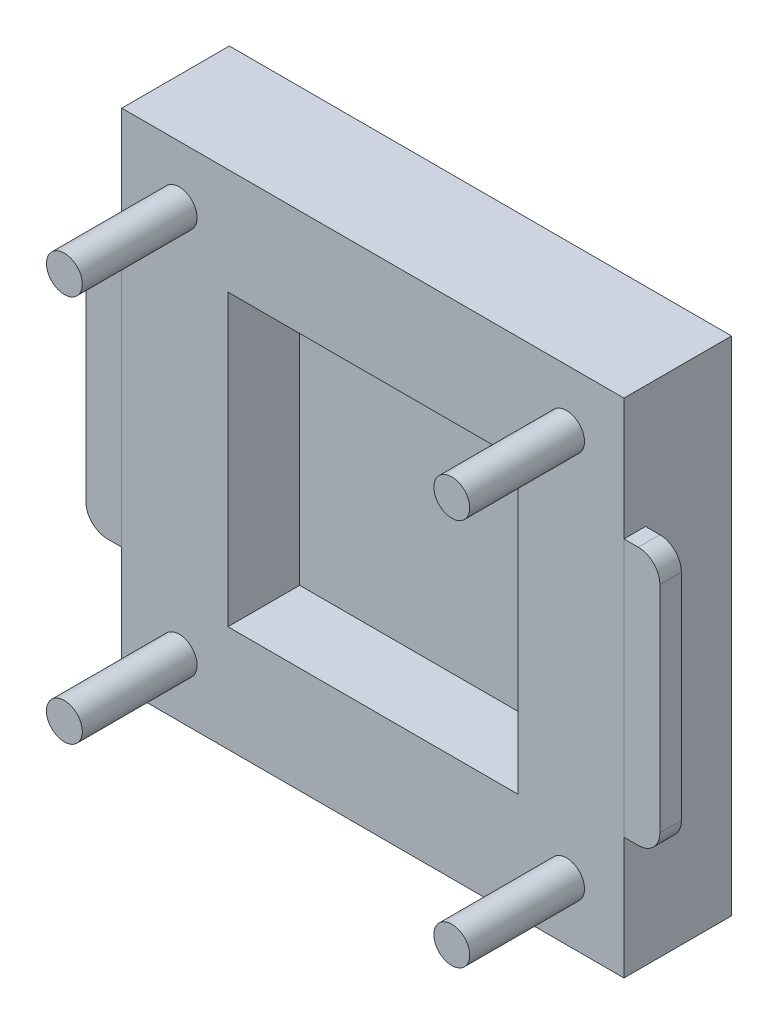
from build123d import *

# Parameters (mm, degrees)
SKETCH_1_W          = 70
SKETCH_1_H          = 70
EXTRUDE_1_DEPTH     = 15
SKETCH_2_W          = 40.4
SKETCH_2_H          = 40.4
CUT_EXTRUDE_1_DEPTH = 10
SKETCH_3_R          = 2.5
EXTRUDE_2_DEPTH     = 16
EXTRUDE_3_DEPTH     = 3
EXTRUDE_3_2_DEPTH   = 3


with BuildPart() as part:
    # 草图1 → 凸台-拉伸1 (new body)
    with BuildSketch(Plane.XY):
        with Locations((35, 35)):
            Rectangle(SKETCH_1_W, SKETCH_1_H)
    extrude(amount=EXTRUDE_1_DEPTH)

    # 草图2 → 切除-拉伸1 (cut)
    with BuildSketch(Plane.XY.offset(15)):
        with Locations((35, 35)):
            Rectangle(SKETCH_2_W, SKETCH_2_H)
    extrude(amount=-CUT_EXTRUDE_1_DEPTH, mode=Mode.SUBTRACT)

    # 草图3 → 凸台-拉伸2 (add)
    with BuildSketch(Plane.XY.offset(15)):
        with Locations((8, 62)):
            Circle(SKETCH_3_R)
        with Locations((62, 62)):
            Circle(SKETCH_3_R)
        with Locations((62, 8)):
            Circle(SKETCH_3_R)
        with Locations((8, 8)):
            Circle(SKETCH_3_R)
    extrude(amount=EXTRUDE_2_DEPTH)


with BuildPart() as body_2:
    # 草图5 → 凸台-拉伸3 (new body)
    with BuildSketch(Plane.XY.offset(15)):
        with BuildLine():
            Line((-2, 53), (0, 53))
            Line((0, 53), (0, 17))
            Line((0, 17), (-2, 17))
            ThreePointArc((-2, 17), (-4.121320344, 17.878679656), (-5, 20))
            Line((-5, 20), (-5, 50))
            ThreePointArc((-5, 50), (-4.121320344, 52.121320344), (-2, 53))
        make_face()
    extrude(amount=-EXTRUDE_3_DEPTH)


with BuildPart() as body_3:
    # 草图5 → Extrude 3 2 (new body)
    with BuildSketch(Plane.XY.offset(15)):
        with BuildLine():
            Line((72, 17), (70, 17))
            Line((70, 17), (70, 53))
            Line((70, 53), (72, 53))
            ThreePointArc((72, 53), (74.121320344, 52.121320344), (75, 50))
            Line((75, 50), (75, 20))
            ThreePointArc((75, 20), (74.121320344, 17.878679656), (72, 17))
        make_face()
    extrude(amount=-EXTRUDE_3_2_DEPTH)


solid = Compound([part.part, body_2.part, body_3.part])
